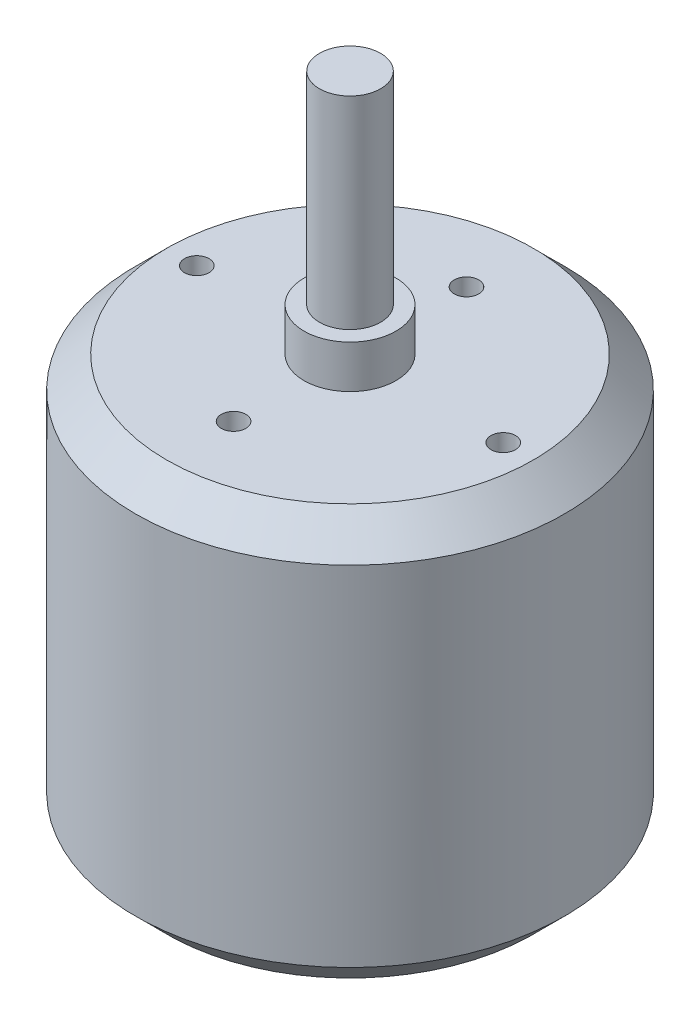
from build123d import *

# Parameters (mm, degrees)
SKETCH1_R           = 17.5
BOSS_EXTRUDE1_DEPTH = 24
SKETCH2_R           = 3.75
BOSS_EXTRUDE2_DEPTH = 3.5
SKETCH3_R           = 2.5
BOSS_EXTRUDE3_DEPTH = 16.5
CHAMFER1_SIZE       = 2.54
SKETCH5_R           = 17.5
BOSS_EXTRUDE4_DEPTH = 9.5
CHAMFER2_SIZE       = 2.54
SKETCH6_R           = 3
BOSS_EXTRUDE5_DEPTH = 1
SKETCH7_R           = 1
CUT_EXTRUDE1_DEPTH  = 25.4


with BuildPart() as part:
    # Sketch1 → Boss-Extrude1 (new body)
    with BuildSketch(Plane(origin=(0, 0, 0), x_dir=(1, 0, 0), z_dir=(0, 1, 0))):
        Circle(SKETCH1_R)
    extrude(amount=BOSS_EXTRUDE1_DEPTH)

    # Sketch2 → Boss-Extrude2 (add)
    with BuildSketch(Plane(origin=(0, 24, 0), x_dir=(1, 0, 0), z_dir=(0, 1, 0))):
        Circle(SKETCH2_R)
    extrude(amount=BOSS_EXTRUDE2_DEPTH)

    # Sketch3 → Boss-Extrude3 (add)
    with BuildSketch(Plane(origin=(0, 27.5, 0), x_dir=(1, 0, 0), z_dir=(0, 1, 0))):
        Circle(SKETCH3_R)
    extrude(amount=BOSS_EXTRUDE3_DEPTH)

    # Chamfer1
    chamfer1_edges = [part.edges().sort_by_distance(p)[0] for p in [
        (-17.5, 24, 0),
    ]]
    chamfer(chamfer1_edges, length=CHAMFER1_SIZE)

    # Sketch5 → Boss-Extrude4 (add)
    with BuildSketch(Plane.XZ):
        Circle(SKETCH5_R)
    extrude(amount=BOSS_EXTRUDE4_DEPTH)

    # Chamfer2
    chamfer2_edges = [part.edges().sort_by_distance(p)[0] for p in [
        (-17.5, -9.5, 0),
    ]]
    chamfer(chamfer2_edges, length=CHAMFER2_SIZE)

    # Sketch6 → Boss-Extrude5 (add)
    with BuildSketch(Plane.XZ.offset(9.5)):
        Circle(SKETCH6_R)
    extrude(amount=BOSS_EXTRUDE5_DEPTH)

    # Sketch7 → Cut-Extrude1 (cut)
    with BuildSketch(Plane(origin=(0, 24, 0), x_dir=(1, 0, 0), z_dir=(0, 1, 0))):
        with Locations((0, 9.5)):
            Circle(SKETCH7_R)
        with Locations((12.5, 0)):
            Circle(SKETCH7_R)
        with Locations((0, -9.5)):
            Circle(SKETCH7_R)
        with Locations((-12.5, 0)):
            Circle(SKETCH7_R)
    extrude(amount=-CUT_EXTRUDE1_DEPTH, mode=Mode.SUBTRACT)


solid = part.part
